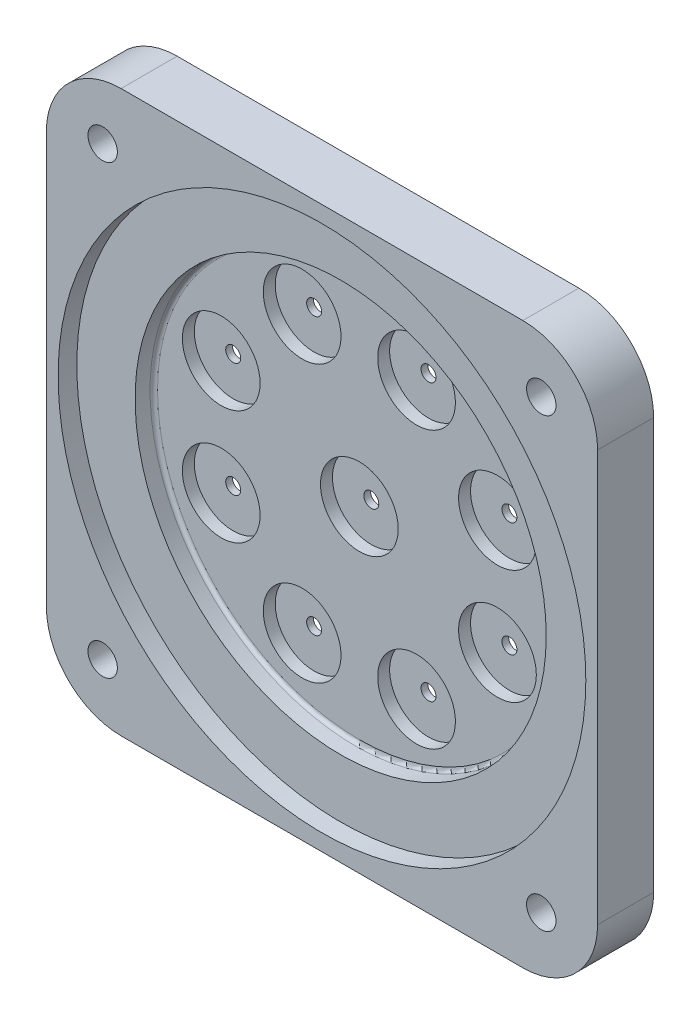
from build123d import *

# Parameters (mm, degrees)
BOSS_EXTRUDE1_DEPTH                     = 19.05
INSET_START                             = 19.05
SKETCH4_R                               = 89.662
INSET_RIM_DEPTH                         = 6.35
CUT_EXTRUDE1_START                      = 12.7
SKETCH9_R                               = 69.85
CUT_EXTRUDE1_DEPTH                      = 6.35
FILLET2_R                               = 1.27
CBORE_FOR_M8_HEX_HEAD_BOLT1_D           = 10
CBORE_FOR_M8_HEX_HEAD_BOLT1_CBORE_D     = 18.011
CBORE_FOR_M8_HEX_HEAD_BOLT1_CBORE_DEPTH = 5.3
SKETCH12_R                              = 2.54
CUT_EXTRUDE2_DEPTH                      = 6.35
SKETCH13_R                              = 13.208
SKETCH13_R_2                            = 2.54
CUT_EXTRUDE3_DEPTH                      = 4.064


with BuildPart() as part:
    # Sketch1 → Boss-Extrude1 (new body)
    with BuildSketch(Plane.XY):
        with BuildLine():
            Line((93.6625, 69.85), (93.6625, -69.85))
            ThreePointArc((93.6625, -69.85), (86.223012242, -87.810512242), (68.2625, -95.25))
            Line((68.2625, -95.25), (-68.2625, -95.25))
            ThreePointArc((-68.2625, -95.25), (-86.223012242, -87.810512242), (-93.6625, -69.85))
            Line((-93.6625, -69.85), (-93.6625, 69.85))
            ThreePointArc((-93.6625, 69.85), (-86.223012242, 87.810512242), (-68.2625, 95.25))
            Line((-68.2625, 95.25), (68.2625, 95.25))
            ThreePointArc((68.2625, 95.25), (86.223012242, 87.810512242), (93.6625, 69.85))
        make_face()
    extrude(amount=BOSS_EXTRUDE1_DEPTH)

    # Sketch4 → Inset Rim (cut)
    with BuildSketch(Plane.XY.offset(INSET_START)):
        Circle(SKETCH4_R)
    extrude(amount=-INSET_RIM_DEPTH, mode=Mode.SUBTRACT)

    # Sketch9 → Cut-Extrude1 (cut)
    with BuildSketch(Plane.XY.offset(CUT_EXTRUDE1_START)):
        Circle(SKETCH9_R)
    extrude(amount=-CUT_EXTRUDE1_DEPTH, mode=Mode.SUBTRACT)

    # Fillet2
    fillet2_edges = [part.edges().sort_by_distance(p)[0] for p in [
        (-69.85, 0, 6.35),
    ]]
    fillet(fillet2_edges, radius=FILLET2_R)

    # CBORE for M8 Hex Head Bolt1 (through all)
    with Locations(Plane(origin=(0, 0, 0), x_dir=(-1, 0, 0), z_dir=(0, 0, -1))):
        with Locations((-74.521339476, -75.893393448), (-74.521339476, 75.893393448), (74.521339476, 75.893393448), (74.521339476, -75.893393448)):
            CounterBoreHole(CBORE_FOR_M8_HEX_HEAD_BOLT1_D / 2, CBORE_FOR_M8_HEX_HEAD_BOLT1_CBORE_D / 2, CBORE_FOR_M8_HEX_HEAD_BOLT1_CBORE_DEPTH)

    # Sketch12 → Cut-Extrude2 (cut)
    with BuildSketch(Plane(origin=(0, 0, 0), x_dir=(-1, 0, 0), z_dir=(0, 0, -1))):
        Circle(SKETCH12_R)
        with Locations((19.440318364, 46.933080252)):
            Circle(SKETCH12_R)
        with Locations((46.933080827, 19.440319753)):
            Circle(SKETCH12_R)
        with Locations((46.933082215, -19.440316401)):
            Circle(SKETCH12_R)
        with Locations((19.440321716, -46.933078863)):
            Circle(SKETCH12_R)
        with Locations((-19.440314437, -46.933080252)):
            Circle(SKETCH12_R)
        with Locations((-46.9330769, -19.440319753)):
            Circle(SKETCH12_R)
        with Locations((-46.933078288, 19.440316401)):
            Circle(SKETCH12_R)
        with Locations((-19.440317789, 46.933078863)):
            Circle(SKETCH12_R)
    extrude(amount=-CUT_EXTRUDE2_DEPTH, mode=Mode.SUBTRACT)

    # Sketch13 → Cut-Extrude3 (cut)
    with BuildSketch(Plane.XY.offset(6.35)):
        with Locations((46.933078863, 19.440317789)):
            Circle(SKETCH13_R)
        with Locations((46.933078288, 19.440316401)):
            Circle(SKETCH13_R_2, mode=Mode.SUBTRACT)
        with Locations((19.440317789, 46.933078863)):
            Circle(SKETCH13_R)
        with Locations((19.440317789, 46.933078863)):
            Circle(SKETCH13_R_2, mode=Mode.SUBTRACT)
        with Locations((46.933078863, -19.440317789)):
            Circle(SKETCH13_R)
        with Locations((46.9330769, -19.440319753)):
            Circle(SKETCH13_R_2, mode=Mode.SUBTRACT)
        with Locations((19.440317789, -46.933078863)):
            Circle(SKETCH13_R)
        with Locations((19.440314437, -46.933080252)):
            Circle(SKETCH13_R_2, mode=Mode.SUBTRACT)
        Circle(SKETCH13_R)
        Circle(SKETCH13_R_2, mode=Mode.SUBTRACT)
        with Locations((-19.440317789, -46.933078863)):
            Circle(SKETCH13_R)
        with Locations((-19.440321716, -46.933078863)):
            Circle(SKETCH13_R_2, mode=Mode.SUBTRACT)
        with Locations((-46.933078863, -19.440317789)):
            Circle(SKETCH13_R)
        with Locations((-46.933082215, -19.440316401)):
            Circle(SKETCH13_R_2, mode=Mode.SUBTRACT)
        with Locations((-46.933078863, 19.440317789)):
            Circle(SKETCH13_R)
        with Locations((-46.933080827, 19.440319753)):
            Circle(SKETCH13_R_2, mode=Mode.SUBTRACT)
        with Locations((-19.440317789, 46.933078863)):
            Circle(SKETCH13_R)
        with Locations((-19.440318364, 46.933080252)):
            Circle(SKETCH13_R_2, mode=Mode.SUBTRACT)
    extrude(amount=-CUT_EXTRUDE3_DEPTH, mode=Mode.SUBTRACT)


solid = part.part
